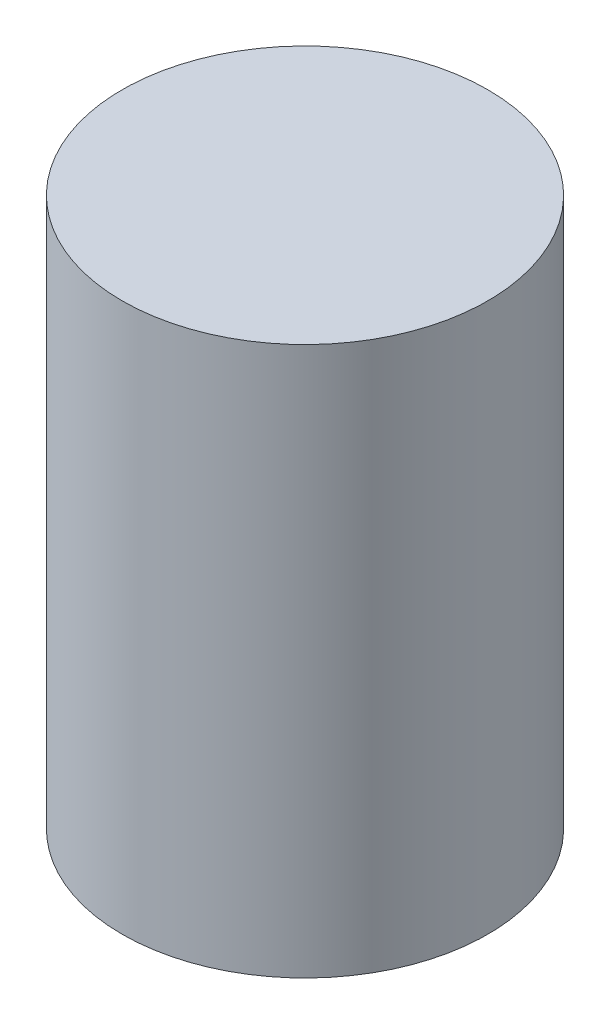
from build123d import *

# Parameters (mm, degrees)
SKETCH1_R           = 3
BOSS_EXTRUDE1_DEPTH = 9


with BuildPart() as part:
    # Sketch1 → Boss-Extrude1 (new body)
    with BuildSketch(Plane(origin=(0, 0, 0), x_dir=(1, 0, 0), z_dir=(0, 1, 0))):
        Circle(SKETCH1_R)
    extrude(amount=BOSS_EXTRUDE1_DEPTH)


solid = part.part
